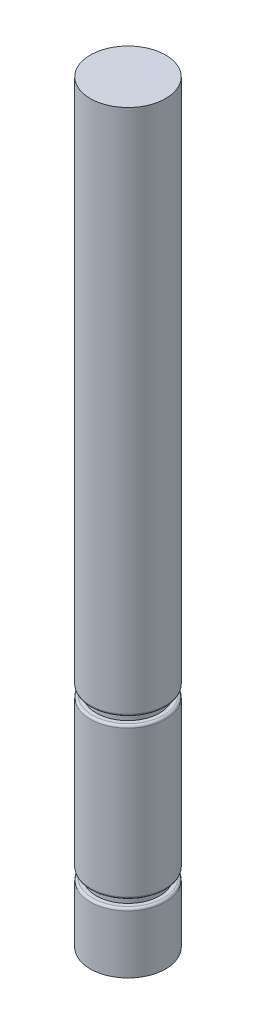
from build123d import *

# Parameters (mm, degrees)
SKETCH1_R           = 5
BOSS_EXTRUDE1_DEPTH = 100
CUT_EXTRUDE1_START  = 29
SKETCH2_R           = 5
SKETCH2_R_2         = 4.2
CUT_EXTRUDE1_DEPTH  = 1
FILLET1_R           = 0.3
CUT_EXTRUDE2_START  = 8
SKETCH2_2_R         = 5
SKETCH2_2_R_2       = 4.2
CUT_EXTRUDE2_DEPTH  = 1
FILLET2_R           = 0.3


with BuildPart() as part:
    # Sketch1 → Boss-Extrude1 (new body)
    with BuildSketch(Plane(origin=(0, 0, 0), x_dir=(1, 0, 0), z_dir=(0, 1, 0))):
        Circle(SKETCH1_R)
    extrude(amount=BOSS_EXTRUDE1_DEPTH)

    # Sketch2 → Cut-Extrude1 (cut)
    with BuildSketch(Plane(origin=(0, 0, 0), x_dir=(1, 0, 0), z_dir=(0, 1, 0)).offset(CUT_EXTRUDE1_START)):
        Circle(SKETCH2_R)
        Circle(SKETCH2_R_2, mode=Mode.SUBTRACT)
    extrude(amount=CUT_EXTRUDE1_DEPTH, mode=Mode.SUBTRACT)

    # Fillet1
    fillet1_edges = [part.edges().sort_by_distance(p)[0] for p in [
        (-5, 30, 0),
        (-5, 29, 0),
    ]]
    fillet(fillet1_edges, radius=FILLET1_R)

    # Sketch2_2 → Cut-Extrude2 (cut)
    with BuildSketch(Plane(origin=(0, 0, 0), x_dir=(1, 0, 0), z_dir=(0, 1, 0)).offset(CUT_EXTRUDE2_START)):
        Circle(SKETCH2_2_R)
        Circle(SKETCH2_2_R_2, mode=Mode.SUBTRACT)
    extrude(amount=CUT_EXTRUDE2_DEPTH, mode=Mode.SUBTRACT)

    # Fillet2
    fillet2_edges = [part.edges().sort_by_distance(p)[0] for p in [
        (-5, 8, 0),
        (-5, 9, 0),
    ]]
    fillet(fillet2_edges, radius=FILLET2_R)


solid = part.part
